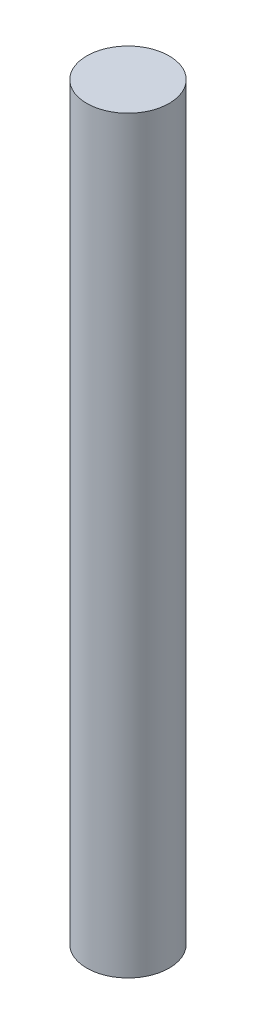
from build123d import *

# Parameters (mm, degrees)
SKETCH1_R           = 2.794
BOSS_EXTRUDE1_DEPTH = 50.8


with BuildPart() as part:
    # Sketch1 → Boss-Extrude1 (new body)
    with BuildSketch(Plane(origin=(0, 0, 0), x_dir=(1, 0, 0), z_dir=(0, 1, 0))):
        Circle(SKETCH1_R)
    extrude(amount=BOSS_EXTRUDE1_DEPTH)


solid = part.part
